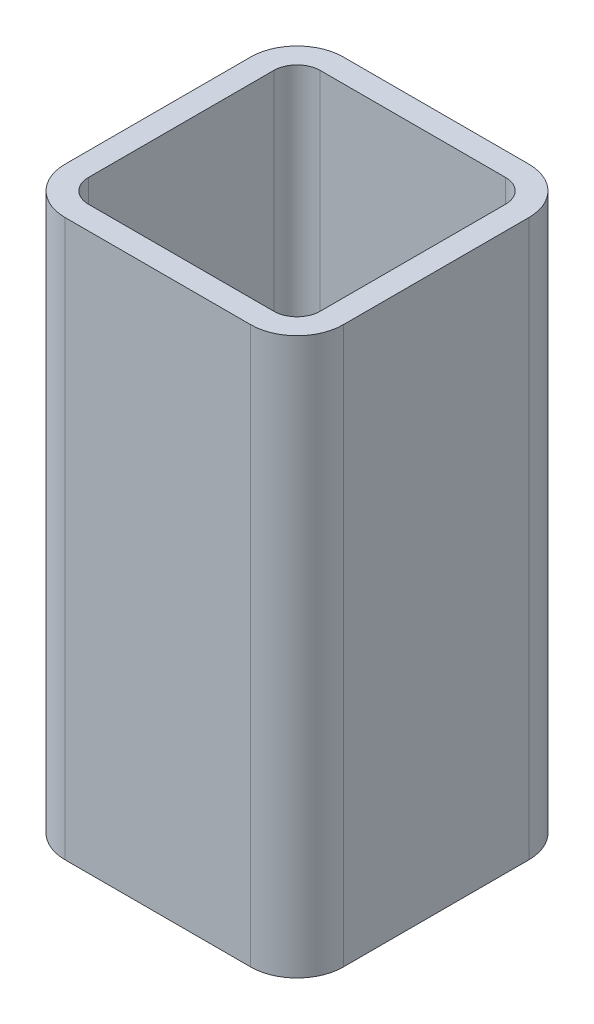
from build123d import *

# Parameters (mm, degrees)
BOSS_EXTRUDE1_DEPTH = 152.4


with BuildPart() as part:
    # Sketch1 → Boss-Extrude1 (new body, symmetric)
    with BuildSketch(Plane(origin=(0, 0, 0), x_dir=(1, 0, 0), z_dir=(0, 1, 0))):
        with BuildLine():
            Line((-50.8, -76.2), (50.8, -76.2))
            ThreePointArc((50.8, -76.2), (68.760512242, -68.760512242), (76.2, -50.8))
            Line((76.2, -50.8), (76.2, 50.8))
            ThreePointArc((76.2, 50.8), (68.760512242, 68.760512242), (50.8, 76.2))
            Line((50.8, 76.2), (-50.8, 76.2))
            ThreePointArc((-50.8, 76.2), (-68.760512242, 68.760512242), (-76.2, 50.8))
            Line((-76.2, 50.8), (-76.2, -50.8))
            ThreePointArc((-76.2, -50.8), (-68.760512242, -68.760512242), (-50.8, -76.2))
        make_face()
        with BuildLine():
            Line((-50.8, -63.5), (50.8, -63.5))
            ThreePointArc((50.8, -63.5), (59.780256121, -59.780256121), (63.5, -50.8))
            Line((63.5, -50.8), (63.5, 50.8))
            ThreePointArc((63.5, 50.8), (59.780256121, 59.780256121), (50.8, 63.5))
            Line((50.8, 63.5), (-50.8, 63.5))
            ThreePointArc((-50.8, 63.5), (-59.780256121, 59.780256121), (-63.5, 50.8))
            Line((-63.5, 50.8), (-63.5, -50.8))
            ThreePointArc((-63.5, -50.8), (-59.780256121, -59.780256121), (-50.8, -63.5))
        make_face(mode=Mode.SUBTRACT)
    extrude(amount=BOSS_EXTRUDE1_DEPTH, both=True)


solid = part.part
